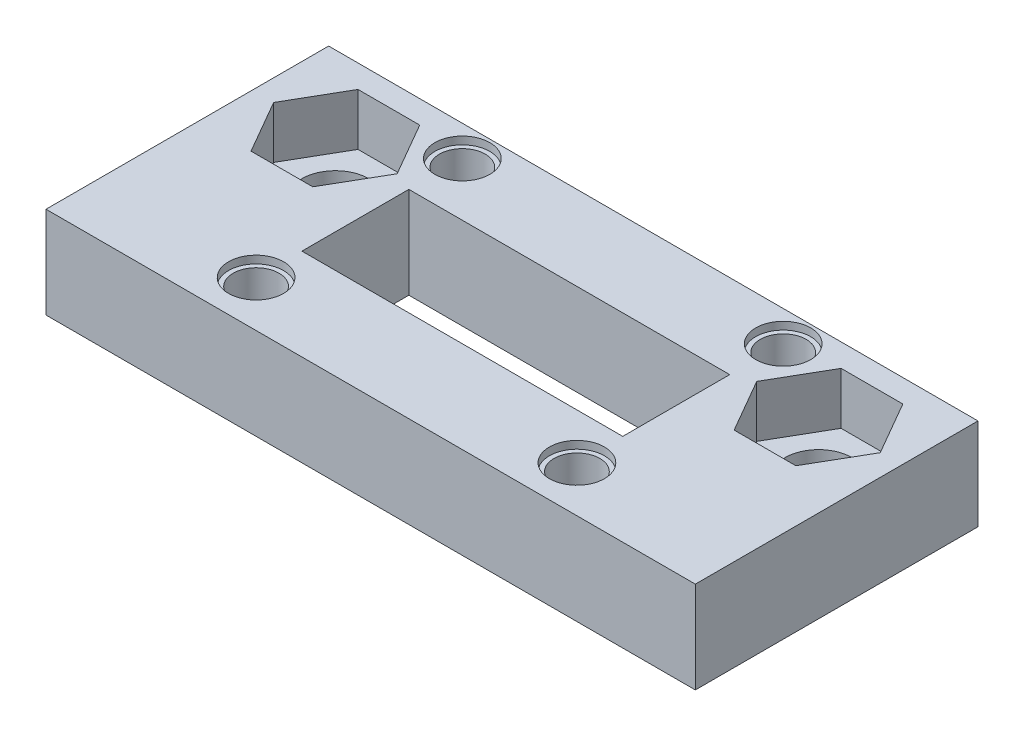
from build123d import *

# Parameters (mm, degrees)
BOSS_EXTRUDE1_DEPTH = 8
SKETCH2_R           = 2.2
CUT_EXTRUDE1_DEPTH  = 20
CUT_EXTRUDE2_DEPTH  = 5.3
SKETCH4_R           = 1.5
CUT_EXTRUDE3_DEPTH  = 4
SKETCH5_R           = 1.8
CUT_EXTRUDE4_DEPTH  = 0.5
CUT_EXTRUDE5_DEPTH  = 3.4
CUT_EXTRUDE6_DEPTH  = 18.4
SKETCH9_W           = 21
SKETCH9_H           = 3
CUT_EXTRUDE8_DEPTH  = 2


with BuildPart() as part:
    # Sketch1 → Boss-Extrude1 (new body)
    with BuildSketch(Plane(origin=(0, 0, 0), x_dir=(1, 0, 0), z_dir=(0, 1, 0))):
        Polygon((-21.25, -18.5), (21.25, -18.5), (21.25, 0), (15.81, 0), (-15.81, 0), (-21.25, 0), align=None)
    extrude(amount=BOSS_EXTRUDE1_DEPTH)

    # Sketch2 → Cut-Extrude1 (cut)
    with BuildSketch(Plane(origin=(0, 8, 0), x_dir=(1, 0, 0), z_dir=(0, 1, 0))):
        with Locations((-15.81, -5)):
            Circle(SKETCH2_R)
        with Locations((15.81, -5)):
            Circle(SKETCH2_R)
    extrude(amount=-CUT_EXTRUDE1_DEPTH, mode=Mode.SUBTRACT)

    # Sketch3 → Cut-Extrude2 (cut)
    with BuildSketch(Plane(origin=(0, 8, 0), x_dir=(1, 0, 0), z_dir=(0, 1, 0))):
        with BuildLine():
            ThreePointArc((-10.5, -14.4), (-11.277817459, -16.277817459), (-9.4, -15.5))
            Line((-9.4, -15.5), (-10.5, -15.5))
            Line((-10.5, -15.5), (-10.5, -14.4))
        make_face()
        with BuildLine():
            Line((-10.5, -15.5), (-9.4, -15.5))
            ThreePointArc((-9.4, -15.5), (-9.722182541, -14.722182541), (-10.5, -14.4))
            Line((-10.5, -14.4), (-10.5, -15.5))
        make_face()
        with BuildLine():
            ThreePointArc((-9.4, -2), (-11.277817459, -1.222182541), (-10.5, -3.1))
            Line((-10.5, -3.1), (-10.5, -2))
            Line((-10.5, -2), (-9.4, -2))
        make_face()
        with BuildLine():
            Line((-10.5, -2), (-10.5, -3.1))
            ThreePointArc((-10.5, -3.1), (-9.722182541, -2.777817459), (-9.4, -2))
            Line((-9.4, -2), (-10.5, -2))
        make_face()
        with BuildLine():
            ThreePointArc((9.4, -2), (9.722182541, -2.777817459), (10.5, -3.1))
            Line((10.5, -3.1), (10.5, -2))
            Line((10.5, -2), (9.4, -2))
        make_face()
        with BuildLine():
            Line((10.5, -2), (10.5, -3.1))
            ThreePointArc((10.5, -3.1), (11.277817459, -2.777817459), (11.6, -2))
            ThreePointArc((11.6, -2), (10.5, -0.9), (9.4, -2))
            Line((9.4, -2), (10.5, -2))
        make_face()
        with BuildLine():
            Line((10.5, -16.6), (10.5, -15.5))
            Line((10.5, -15.5), (9.4, -15.5))
            ThreePointArc((9.4, -15.5), (9.722182541, -16.277817459), (10.5, -16.6))
        make_face()
        with BuildLine():
            Line((10.5, -14.4), (10.5, -15.5))
            Line((10.5, -15.5), (10.5, -16.6))
            ThreePointArc((10.5, -16.6), (11.277817459, -16.277817459), (11.6, -15.5))
            ThreePointArc((11.6, -15.5), (11.277817459, -14.722182541), (10.5, -14.4))
        make_face()
        with BuildLine():
            Line((9.4, -15.5), (10.5, -15.5))
            Line((10.5, -15.5), (10.5, -14.4))
            ThreePointArc((10.5, -14.4), (9.722182541, -14.722182541), (9.4, -15.5))
        make_face()
    extrude(amount=-CUT_EXTRUDE2_DEPTH, mode=Mode.SUBTRACT)

    # Sketch4 → Cut-Extrude3 (cut)
    with BuildSketch(Plane(origin=(0, 8, 0), x_dir=(1, 0, 0), z_dir=(0, 1, 0))):
        with Locations((-10.5, -2)):
            Circle(SKETCH4_R)
        with Locations((10.5, -2)):
            Circle(SKETCH4_R)
        with Locations((-10.5, -15.5)):
            Circle(SKETCH4_R)
        with Locations((10.5, -15.5)):
            Circle(SKETCH4_R)
    extrude(amount=-CUT_EXTRUDE3_DEPTH, mode=Mode.SUBTRACT)

    # Sketch5 → Cut-Extrude4 (cut)
    with BuildSketch(Plane(origin=(0, 8, 0), x_dir=(1, 0, 0), z_dir=(0, 1, 0))):
        with Locations((-10.5, -2)):
            Circle(SKETCH5_R)
        with Locations((10.5, -2)):
            Circle(SKETCH5_R)
        with Locations((-10.5, -15.5)):
            Circle(SKETCH5_R)
        with Locations((10.5, -15.5)):
            Circle(SKETCH5_R)
    extrude(amount=-CUT_EXTRUDE4_DEPTH, mode=Mode.SUBTRACT)

    # Sketch6 → Cut-Extrude5 (cut)
    with BuildSketch(Plane(origin=(0, 8, 0), x_dir=(1, 0, 0), z_dir=(0, 1, 0))):
        Polygon((-11.768548116, -5), (-13.789274058, -1.5), (-17.830725942, -1.5), (-19.851451884, -5), (-17.830725942, -8.5), (-13.789274058, -8.5), align=None)
        Polygon((19.851451884, -5), (17.830725942, -1.5), (13.789274058, -1.5), (11.768548116, -5), (13.789274058, -8.5), (17.830725942, -8.5), align=None)
    extrude(amount=-CUT_EXTRUDE5_DEPTH, mode=Mode.SUBTRACT)

    # Sketch7 → Cut-Extrude6 (cut)
    with BuildSketch(Plane(origin=(0, 8, 0), x_dir=(1, 0, 0), z_dir=(0, 1, 0))):
        Polygon((10.5, -9), (10.5, -5.5), (-10.5, -5.5), (-10.5, -12.5), (10.5, -12.5), align=None)
    extrude(amount=-CUT_EXTRUDE6_DEPTH, mode=Mode.SUBTRACT)

    # Sketch9 → Cut-Extrude8 (cut)
    with BuildSketch(Plane.XZ):
        Polygon((-10.5, 15.5), (10.5, 15.5), (10.5, 18.5), (-21.25, 18.5), (-21.25, 0), (-15.81, 0), (0, 0), (0, 2), (-10.5, 2), (-10.5, 5.5), (-10.5, 12.5), align=None)
        with BuildLine():
            ThreePointArc((-13.61, 5), (-14.254365081, 3.444365081), (-15.81, 2.8))
            ThreePointArc((-15.81, 2.8), (-17.365634919, 6.555634919), (-13.61, 5))
        make_face(mode=Mode.SUBTRACT)
        with Locations((0, 14)):
            Rectangle(SKETCH9_W, SKETCH9_H)
        Polygon((10.5, 2), (10.5, 5.5), (-10.5, 5.5), (-10.5, 2), (0, 2), align=None)
        Polygon((10.5, 18.5), (10.5, 15.5), (10.5, 12.5), (10.5, 5.5), (10.5, 2), (0, 2), (0, 0), (15.81, 0), (21.25, 0), (21.25, 18.5), align=None)
        with BuildLine():
            ThreePointArc((18.01, 5), (17.365634919, 3.444365081), (15.81, 2.8))
            ThreePointArc((15.81, 2.8), (14.254365081, 6.555634919), (18.01, 5))
        make_face(mode=Mode.SUBTRACT)
    extrude(amount=-CUT_EXTRUDE8_DEPTH, mode=Mode.SUBTRACT)


solid = part.part
